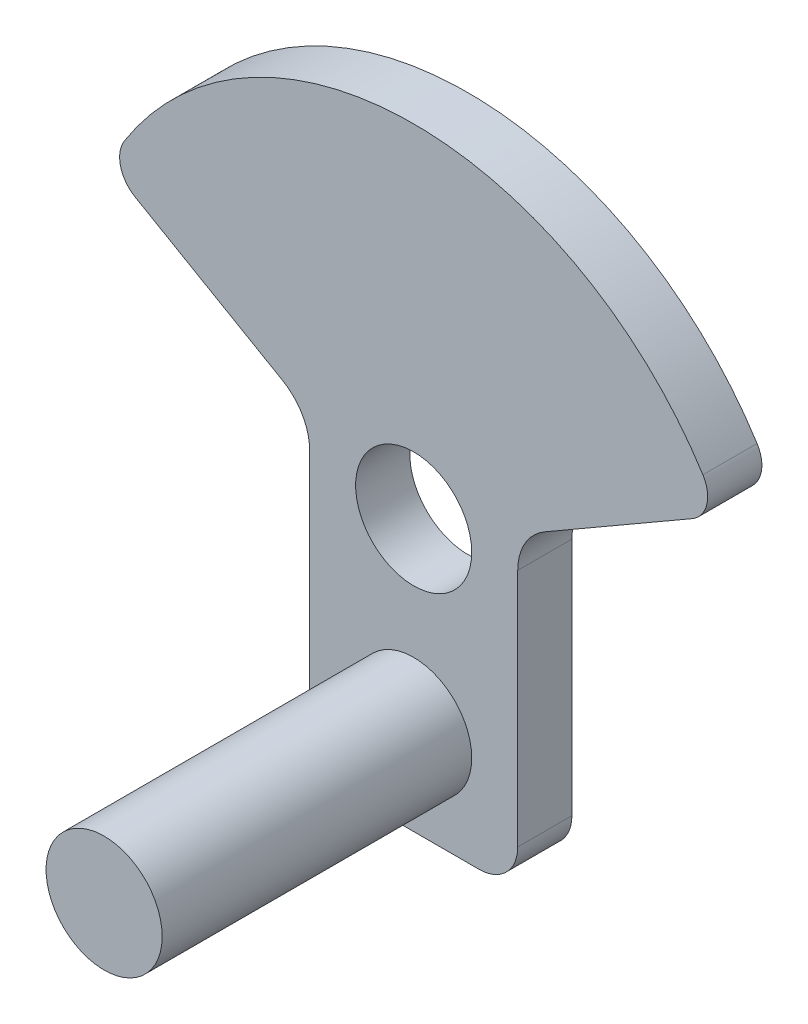
from build123d import *

# Parameters (mm, degrees)
SKETCH2_R           = 7.5
BOSS_EXTRUDE5_DEPTH = 7
SKETCH3_R           = 7.5
BOSS_EXTRUDE6_DEPTH = 40


with BuildPart() as part:
    # Sketch2 → Boss-Extrude5 (new body)
    with BuildSketch(Plane.XY):
        with BuildLine():
            Line((5, 0), (21.89510984, 0))
            ThreePointArc((21.89510984, 0), (25.430643746, 1.464466094), (26.89510984, 5))
            Line((26.89510984, 5), (26.89510984, 35.958548116))
            ThreePointArc((26.89510984, 35.958548116), (27.832932013, 39.458548116), (30.39510984, 42.020725942))
            Line((30.39510984, 42.020725942), (49.440130583, 53.016373795))
            ThreePointArc((49.440130583, 53.016373795), (51.323745621, 55.522595335), (50.821570497, 58.61726368))
            ThreePointArc((50.821570497, 58.61726368), (13.44755492, 79.210770001), (-23.926460657, 58.61726368))
            ThreePointArc((-23.926460657, 58.61726368), (-24.428635781, 55.522595335), (-22.545020743, 53.016373795))
            Line((-22.545020743, 53.016373795), (-3.5, 42.020725942))
            ThreePointArc((-3.5, 42.020725942), (-0.937822174, 39.458548116), (0, 35.958548116))
            Line((0, 35.958548116), (0, 5))
            ThreePointArc((0, 5), (1.464466094, 1.464466094), (5, 0))
        make_face()
        with Locations((13.44755492, 35)):
            Circle(SKETCH2_R, mode=Mode.SUBTRACT)
    extrude(amount=BOSS_EXTRUDE5_DEPTH)

    # Sketch3 → Boss-Extrude6 (add)
    with BuildSketch(Plane.XY.offset(7)):
        with Locations((13.44755492, 12)):
            Circle(SKETCH3_R)
    extrude(amount=BOSS_EXTRUDE6_DEPTH)


solid = part.part
